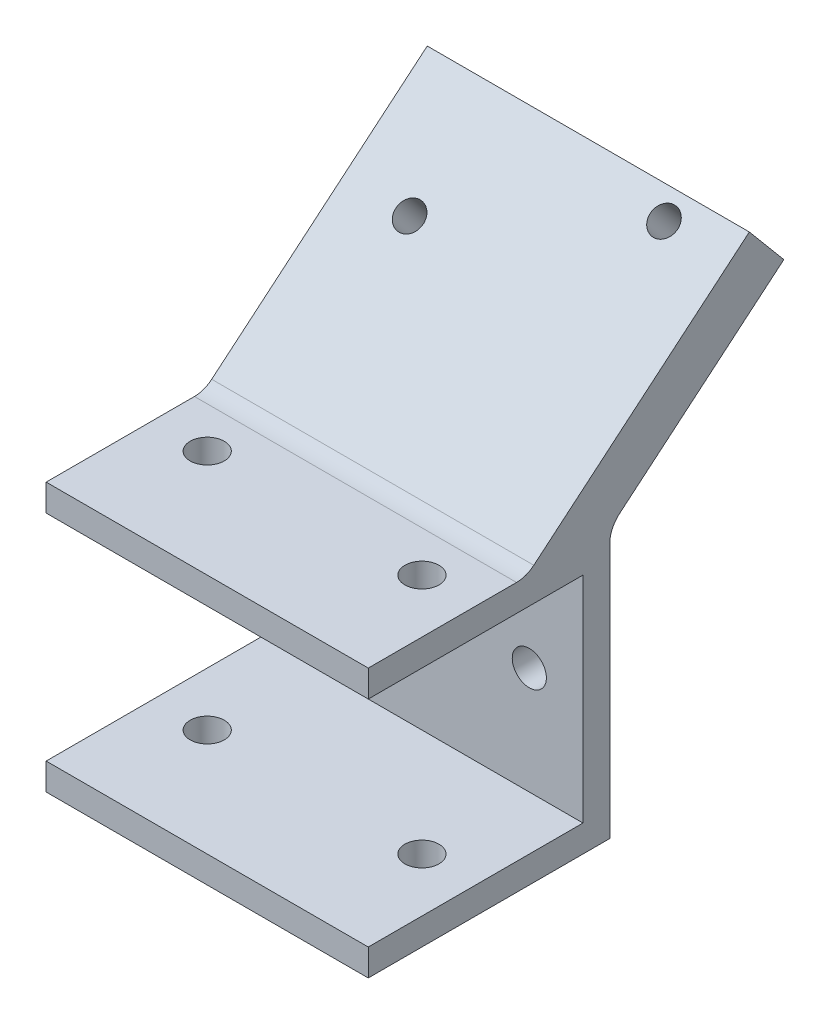
from build123d import *

# Parameters (mm, degrees)
BOSS_EXTRUDE1_DEPTH = 38.1
SKETCH2_R           = 2.0193
CUT_EXTRUDE1_DEPTH  = 38.862
BOSS_EXTRUDE2_DEPTH = 38.1
FILLET1_R           = 3.175
CIRPATTERN1_COUNT   = 2
CIRPATTERN1_ANGLE   = 90
SKETCH6_R           = 1.625
CUT_EXTRUDE2_DEPTH  = 28.575


with BuildPart() as part:
    # Sketch1 → Boss-Extrude1 (new body)
    with BuildSketch(Plane(origin=(0, 0, 0), x_dir=(0, 0, -1), z_dir=(1, 0, 0))):
        Polygon((-12.7, 12.7), (12.7, 12.7), (12.7, -12.7), (-12.7, -12.7), (-12.7, -15.875), (15.875, -15.875), (15.875, 15.875), (-12.7, 15.875), align=None)
    extrude(amount=BOSS_EXTRUDE1_DEPTH)

    # Sketch2 → Cut-Extrude1 (cut)
    with BuildSketch(Plane(origin=(0, 15.875, 0), x_dir=(1, 0, 0), z_dir=(0, 1, 0))):
        with Locations((6.35, 0)):
            Circle(SKETCH2_R)
        with Locations((31.75, 0)):
            Circle(SKETCH2_R)
    cut_extrude1 = extrude(amount=-CUT_EXTRUDE1_DEPTH, mode=Mode.SUBTRACT)

    # Sketch5 → Boss-Extrude2 (add)
    with BuildSketch(Plane(origin=(38.1, 0, 0), x_dir=(0, 0, -1), z_dir=(1, 0, 0))):
        Polygon((15.875, 15.875), (36.45820813, 33.146238), (32.376524054, 38.010634684), (5.996111961, 15.875), align=None)
    extrude(amount=-BOSS_EXTRUDE2_DEPTH)

    # Fillet1
    fillet1_edges = [part.edges().sort_by_distance(p)[0] for p in [
        (19.05, 15.875, -15.875),
        (19.05, 15.875, -5.996111961),
    ]]
    fillet(fillet1_edges, radius=FILLET1_R)

    # CirPattern1: Cut-Extrude1 ×2 about axis
    cirpattern1_axis = Axis((21.2725, 0, 0), (-1, 0, 0))
    for i in range(1, CIRPATTERN1_COUNT):
        add(cut_extrude1.rotate(cirpattern1_axis, i * CIRPATTERN1_ANGLE / (CIRPATTERN1_COUNT - 1)), mode=Mode.SUBTRACT)

    # Sketch6 → Cut-Extrude2 (cut)
    with BuildSketch(Plane(origin=(0, 6.363382753, 5.339473678), x_dir=(1, 0, 0), z_dir=(0, 0.7660467219358679, 0.6427848938885473))):
        with Locations((7.95, 36.134591901)):
            Circle(SKETCH6_R)
        with Locations((30.15, 46.434591901)):
            Circle(SKETCH6_R)
    extrude(amount=-CUT_EXTRUDE2_DEPTH, mode=Mode.SUBTRACT)


solid = part.part
